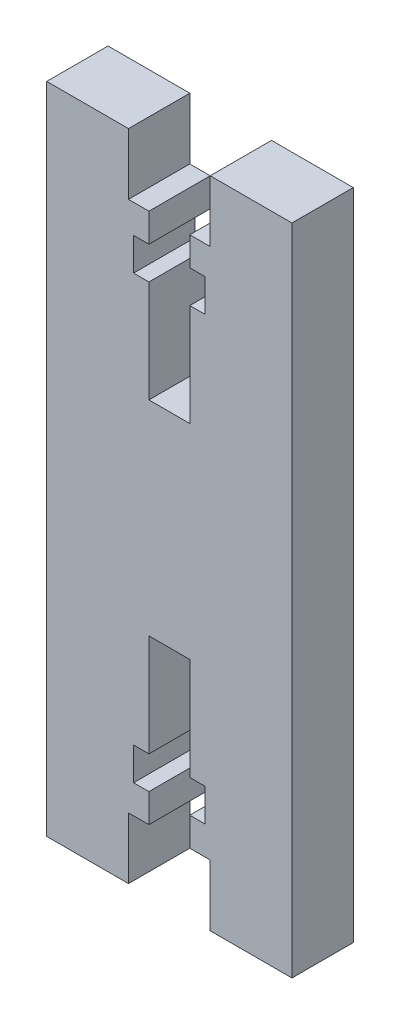
from build123d import *

# Parameters (mm, degrees)
BOSS_EXTRU_1_DEPTH = 6


with BuildPart() as part:
    # Esquisse1 → Boss.-Extru.1 (new body)
    with BuildSketch(Plane.XY):
        Polygon((8, 0), (8, 6), (10, 6), (10, 8.8), (8.5, 8.8), (8.5, 12), (10, 12), (10, 22), (14, 22), (14, 12), (15.5, 12), (15.5, 8.8), (14, 8.8), (14, 6), (16, 6), (16, 0), (24, 0), (24, 64), (16, 64), (16, 58), (14, 58), (14, 55.2), (15.5, 55.2), (15.5, 52), (14, 52), (14, 42), (10, 42), (10, 52), (8.5, 52), (8.5, 55.2), (10, 55.2), (10, 58), (8, 58), (8, 64), (0, 64), (0, 0), align=None)
    extrude(amount=BOSS_EXTRU_1_DEPTH)


solid = part.part
